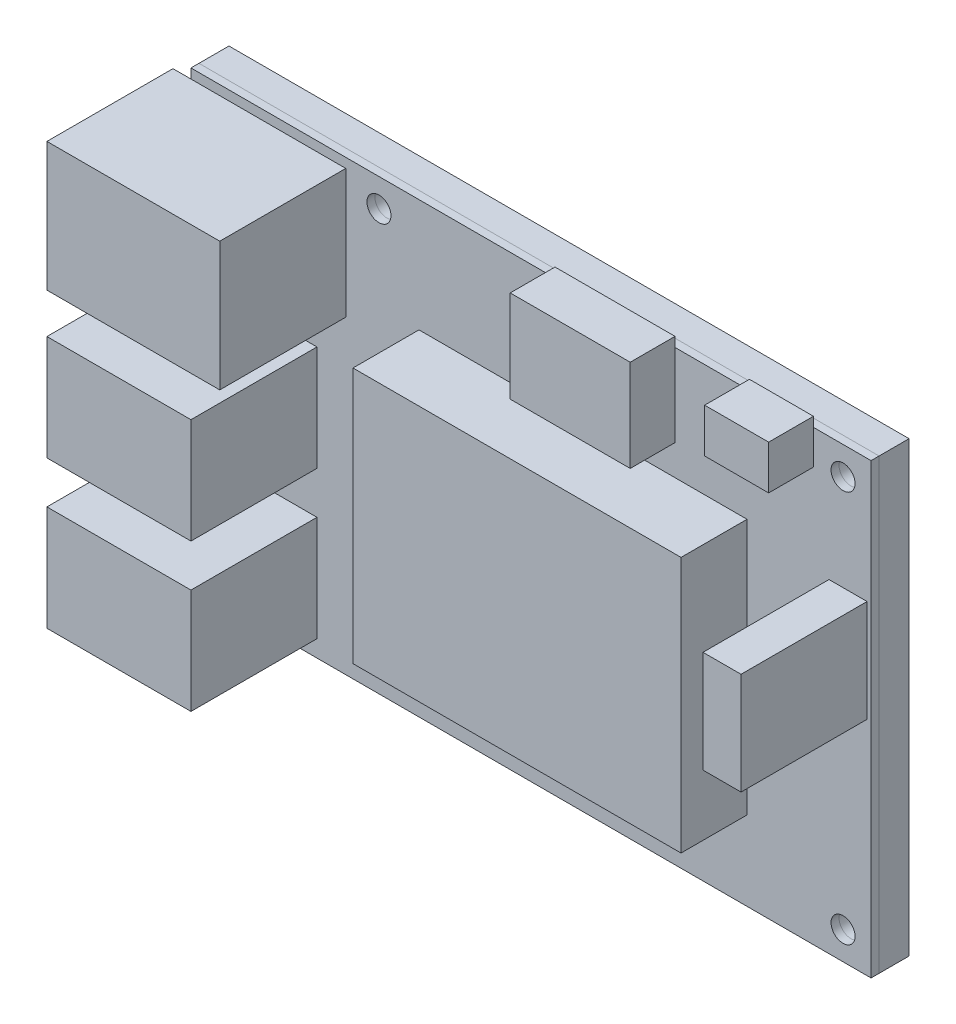
from build123d import *

# Parameters (mm, degrees)
SKETCH1_W           = 85
SKETCH1_H           = 56
SKETCH1_R           = 1.5
BOSS_EXTRUDE1_DEPTH = 1
SKETCH1_2_W         = 85
SKETCH1_2_H         = 56
SKETCH1_2_R         = 1.5
BOSS_EXTRUDE2_DEPTH = 3.75
SKETCH3_W           = 41
SKETCH3_H           = 32
BOSS_EXTRUDE3_DEPTH = 8.25
SKETCH4_W           = 18
SKETCH4_H           = 13.14
SKETCH4_W_2         = 4.755
SKETCH4_H_2         = 12.75
SKETCH4_W_3         = 21.6
SKETCH4_H_3         = 16.1
BOSS_EXTRUDE4_DEPTH = 15.75
SKETCH5_W           = 15
SKETCH5_H           = 11.5
SKETCH5_W_2         = 8
SKETCH5_H_2         = 5.5
BOSS_EXTRUDE5_DEPTH = 5.6
SKETCH6_W           = 11.61
SKETCH6_H           = 15.75
BOSS_EXTRUDE6_DEPTH = 4


with BuildPart() as part:
    # Sketch1 → Boss-Extrude1 (new body)
    with BuildSketch(Plane.XY):
        Rectangle(SKETCH1_W, SKETCH1_H)
        with Locations((-19.000000078, 24.5)):
            Circle(SKETCH1_R, mode=Mode.SUBTRACT)
        with Locations((-19.000000078, -24.5)):
            Circle(SKETCH1_R, mode=Mode.SUBTRACT)
        with Locations((39, 24.5)):
            Circle(SKETCH1_R, mode=Mode.SUBTRACT)
        with Locations((39, -24.5)):
            Circle(SKETCH1_R, mode=Mode.SUBTRACT)
    extrude(amount=BOSS_EXTRUDE1_DEPTH)

    # Sketch3 → Boss-Extrude3 (add)
    with BuildSketch(Plane.XY.offset(1)):
        with Locations((6.5, -2.1)):
            Rectangle(SKETCH3_W, SKETCH3_H)
    extrude(amount=BOSS_EXTRUDE3_DEPTH)

    # Sketch4 → Boss-Extrude4 (add)
    with BuildSketch(Plane.XY.offset(1)):
        with Locations((-35.74947609, -0.89)):
            Rectangle(SKETCH4_W, SKETCH4_H)
        with Locations((-35.74947609, -19.33)):
            Rectangle(SKETCH4_W, SKETCH4_H)
        with Locations((39.6225, 6.125)):
            Rectangle(SKETCH4_W_2, SKETCH4_H_2)
        with Locations((-33.94947609, 18.75)):
            Rectangle(SKETCH4_W_3, SKETCH4_H_3)
    extrude(amount=BOSS_EXTRUDE4_DEPTH)

    # Sketch5 → Boss-Extrude5 (add)
    with BuildSketch(Plane.XY.offset(1)):
        with Locations((10.5, 23.45)):
            Rectangle(SKETCH5_W, SKETCH5_H)
        with Locations((31.3, 26.45)):
            Rectangle(SKETCH5_W_2, SKETCH5_H_2)
    extrude(amount=BOSS_EXTRUDE5_DEPTH)


with BuildPart() as body_2:
    # Sketch1_2 → Boss-Extrude2 (new body)
    with BuildSketch(Plane.XY):
        Rectangle(SKETCH1_2_W, SKETCH1_2_H)
        with Locations((-19.000000078, 24.5)):
            Circle(SKETCH1_2_R, mode=Mode.SUBTRACT)
        with Locations((-19.000000078, -24.5)):
            Circle(SKETCH1_2_R, mode=Mode.SUBTRACT)
        with Locations((39, 24.5)):
            Circle(SKETCH1_2_R, mode=Mode.SUBTRACT)
        with Locations((39, -24.5)):
            Circle(SKETCH1_2_R, mode=Mode.SUBTRACT)
    extrude(amount=-BOSS_EXTRUDE2_DEPTH)


with BuildPart() as body_3:
    # Sketch6 → Boss-Extrude6 (new body)
    with BuildSketch(Plane.XY):
        with Locations((-6.401910681, -20.625)):
            Rectangle(SKETCH6_W, SKETCH6_H)
    extrude(amount=-BOSS_EXTRUDE6_DEPTH)


solid = Compound([part.part, body_2.part, body_3.part])
